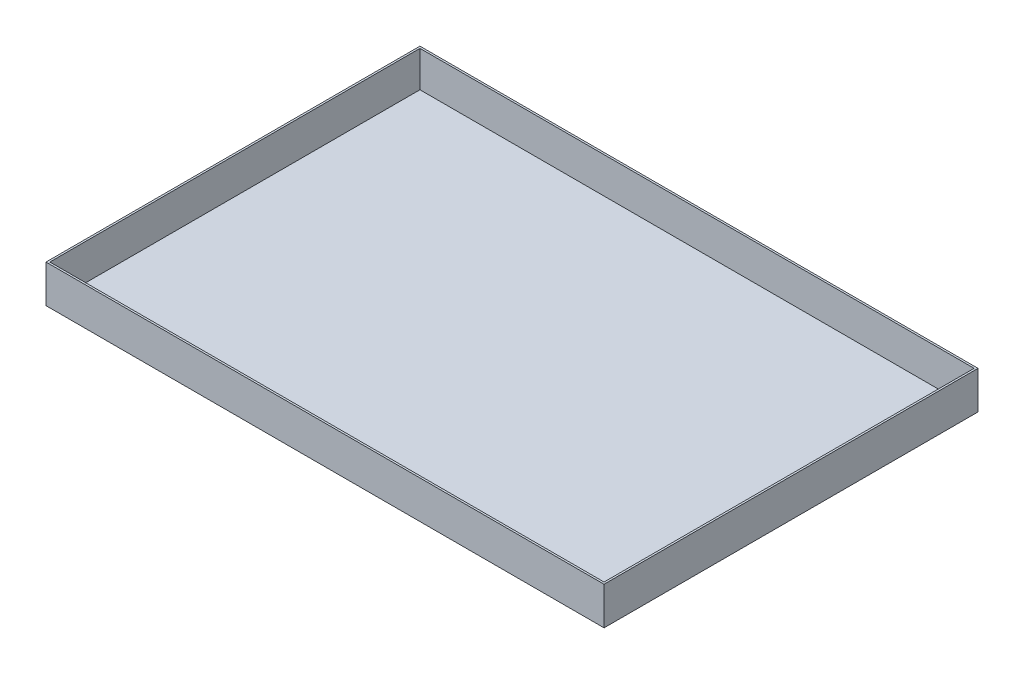
from build123d import *

# Parameters (mm, degrees)
SKETCH1_W           = 923.925
SKETCH1_H           = 619.125
BOSS_EXTRUDE1_DEPTH = 3.175
SKETCH2_W           = 3.175
SKETCH2_H           = 619.125
BOSS_EXTRUDE2_DEPTH = 59.4
SKETCH3_W           = 917.575
SKETCH3_H           = 3.175
BOSS_EXTRUDE3_DEPTH = 59.4


with BuildPart() as part:
    # Sketch1 → Boss-Extrude1 (new body)
    with BuildSketch(Plane(origin=(0, 0, 0), x_dir=(1, 0, 0), z_dir=(0, 1, 0))):
        with Locations((461.9625, 309.5625)):
            Rectangle(SKETCH1_W, SKETCH1_H)
    extrude(amount=BOSS_EXTRUDE1_DEPTH)

    # Sketch2 → Boss-Extrude2 (add)
    with BuildSketch(Plane(origin=(0, 3.175, 0), x_dir=(1, 0, 0), z_dir=(0, 1, 0))):
        with Locations((1.5875, 309.5625)):
            Rectangle(SKETCH2_W, SKETCH2_H)
        with Locations((922.3375, 309.5625)):
            Rectangle(SKETCH2_W, SKETCH2_H)
    extrude(amount=BOSS_EXTRUDE2_DEPTH)

    # Sketch3 → Boss-Extrude3 (add)
    with BuildSketch(Plane(origin=(0, 3.175, 0), x_dir=(1, 0, 0), z_dir=(0, 1, 0))):
        with Locations((461.9625, 1.5875)):
            Rectangle(SKETCH3_W, SKETCH3_H)
        with Locations((461.9625, 617.5375)):
            Rectangle(SKETCH3_W, SKETCH3_H)
    extrude(amount=BOSS_EXTRUDE3_DEPTH)


solid = part.part
